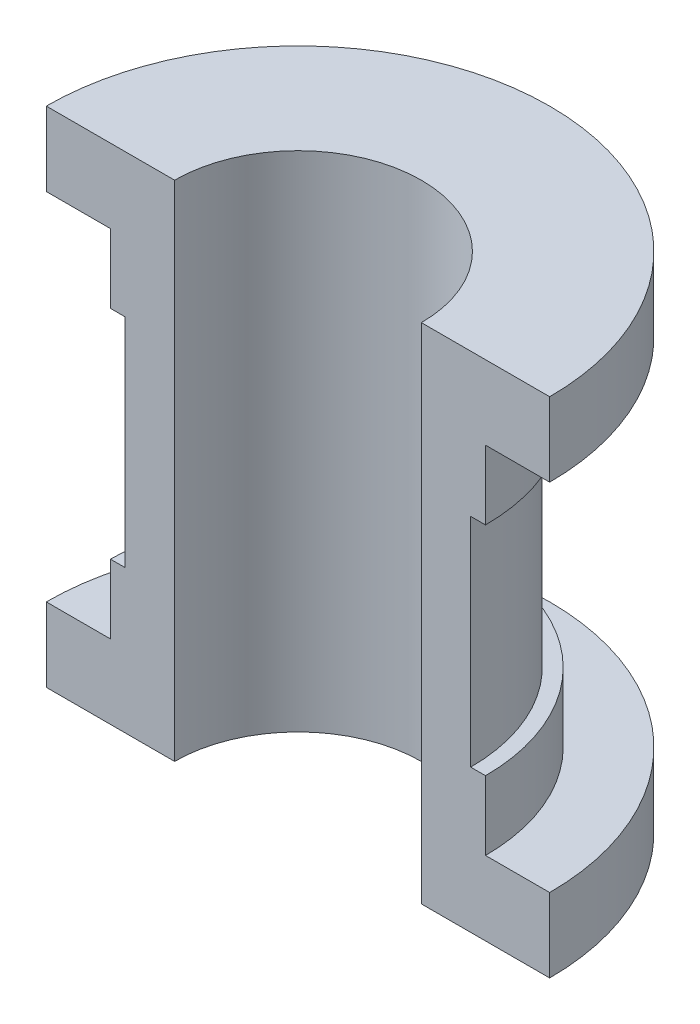
from build123d import *

# Parameters (mm, degrees)
REVOLVE1_ANGLE           = 180
CUT_EXTRUDE1_DEPTH       = 52
BOSS_EXTRUDE1_REACH      = 25.5
BOSS_EXTRUDE1_END_RADIUS = 17.5
SKETCH7_R                = 3


with BuildPart() as part:
    # Sketch3 → Revolve1 (revolve)
    with BuildSketch(Plane.XY):
        Polygon((0, 0), (25.5, 0), (25.5, 7.5), (19, 7.5), (19, 14.5), (17.5, 14.5), (17.5, 36.5), (19, 36.5), (19, 43.5), (25.5, 43.5), (25.5, 51), (0, 51), align=None)
    revolve(axis=Axis((0, 0, 0), (0, 1, 0)), revolution_arc=REVOLVE1_ANGLE)

    # Sketch4 → Cut-Extrude1 (cut, through all)
    with BuildSketch(Plane(origin=(0, 51, 0), x_dir=(1, 0, 0), z_dir=(0, 1, 0))):
        with BuildLine():
            Line((-12.5, 0), (12.5, 0))
            ThreePointArc((12.5, 0), (0, 12.5), (-12.5, 0))
        make_face()
    extrude(amount=-CUT_EXTRUDE1_DEPTH, mode=Mode.SUBTRACT)

    # Boss-Extrude1: up to this cylinder (the profile starts outside it)
    boss_extrude1_end = Plane(origin=(0, 25.5, 0), z_dir=(0, -1, 0)) * Cylinder(BOSS_EXTRUDE1_END_RADIUS, 87, mode=Mode.PRIVATE)
    # Sketch7 → Boss-Extrude1 (add, up to the surface)
    with BuildSketch(Plane(origin=(0, 0, -23.5), x_dir=(-1, 0, 0), z_dir=(0, 0, -1)), mode=Mode.PRIVATE) as boss_extrude1_sk1:
        with Locations((0, 25.5)):
            Circle(SKETCH7_R)
    boss_extrude1_tool1 = extrude(boss_extrude1_sk1.sketch, amount=-BOSS_EXTRUDE1_REACH, mode=Mode.PRIVATE) - boss_extrude1_end
    add(boss_extrude1_tool1.solids().sort_by_distance((0, 25.5, -23.5))[0])


solid = part.part
